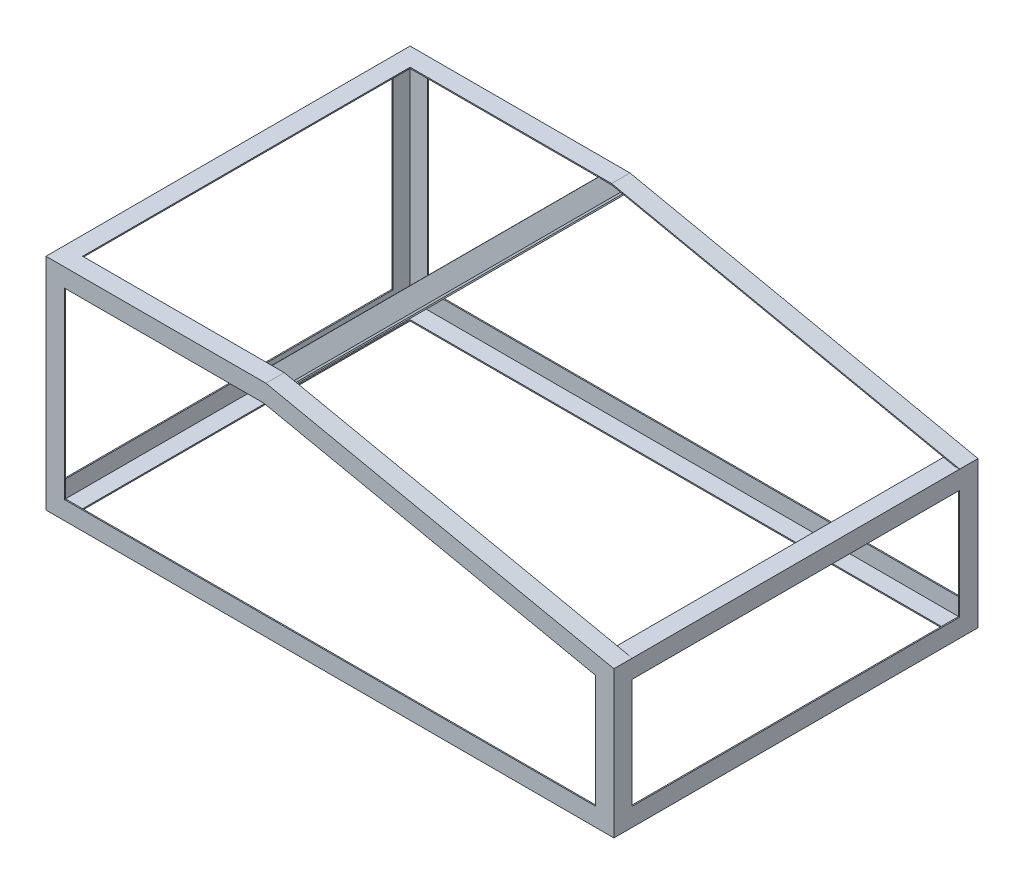
from build123d import *

# Parameters (mm, degrees)
BOTTOM_HORIZONTAL_ANGLE_DEPTH   = 1574.8
BOTTOM_HORIZONTAL_ANGLE_2_DEPTH = 1574.8
FRONT_VERTIAL_ANGLE_DEPTH       = 406.4
REAR_VERTICAL_ANGLE_DEPTH       = 609.6
REAR_TOP_HORIZONTAL_ANGLE_DEPTH = 609.6
BOSS_EXTRUDE5_DEPTH             = 986.357582
BOSS_EXTRUDE6_REACH             = 1011.65


with BuildPart() as part:
    # Sketch5 → Bottom Horizontal Angle (new body)
    with BuildSketch(Plane(origin=(0, 0, 0), x_dir=(0, 0, -1), z_dir=(1, 0, 0))):
        Polygon((-504.825, -304.8), (-504.825, -254), (-501.65, -254), (-501.65, -301.625), (-454.025, -301.625), (-454.025, -304.8), align=None)
    extrude(amount=BOTTOM_HORIZONTAL_ANGLE_DEPTH)



with BuildPart() as body_2:
    # Sketch5 → Bottom Horizontal Angle 2 (new body)
    with BuildSketch(Plane(origin=(0, 0, 0), x_dir=(0, 0, -1), z_dir=(1, 0, 0))):
        Polygon((501.65, -254), (504.825, -254), (504.825, -304.8), (454.025, -304.8), (454.025, -301.625), (501.65, -301.625), align=None)
    extrude(amount=BOTTOM_HORIZONTAL_ANGLE_2_DEPTH)


with BuildPart() as part_1:
    add(part.part)

    add(body_2.part)  # Front Vertial Angle merges body 2
    # Sketch6 → Front Vertial Angle (add)
    with BuildSketch(Plane.XZ.offset(304.8)):
        Polygon((1574.8, -504.825), (1524, -504.825), (1524, -501.65), (1571.625, -501.65), (1571.625, -454.025), (1574.8, -454.025), align=None)
        Polygon((1524, 501.65), (1524, 504.825), (1574.8, 504.825), (1574.8, 454.025), (1571.625, 454.025), (1571.625, 501.65), align=None)
    extrude(amount=-FRONT_VERTIAL_ANGLE_DEPTH)

    # Sketch7 → Rear Vertical Angle (add)
    with BuildSketch(Plane.XZ.offset(304.8)):
        Polygon((0, 504.825), (50.8, 504.825), (50.8, 501.65), (3.175, 501.65), (3.175, 454.025), (0, 454.025), align=None)
        Polygon((50.8, -501.65), (50.8, -504.825), (0, -504.825), (0, -454.025), (3.175, -454.025), (3.175, -501.65), align=None)
    extrude(amount=-REAR_VERTICAL_ANGLE_DEPTH)

    # Sketch8 → Rear Top Horizontal Angle (add)
    with BuildSketch(Plane.ZY):
        Polygon((504.825, 304.8), (504.825, 254), (501.65, 254), (501.65, 301.625), (454.025, 301.625), (454.025, 304.8), align=None)
        Polygon((-501.65, 254), (-504.825, 254), (-504.825, 304.8), (-454.025, 304.8), (-454.025, 301.625), (-501.65, 301.625), align=None)
    extrude(amount=-REAR_TOP_HORIZONTAL_ANGLE_DEPTH)

    # Sketch10 → Boss-Extrude5 (add)
    with BuildSketch(Plane(origin=(522.283289125, -109.954376658, 0), x_dir=(0, 0, -1), z_dir=(0.978549785, -0.206010481, 0))):
        Polygon((504.825, 423.845963712), (504.825, 373.045963712), (501.65, 373.045963712), (501.65, 420.670963712), (454.025, 420.670963712), (454.025, 423.845963712), align=None)
        Polygon((-501.65, 373.045963712), (-504.825, 373.045963712), (-504.825, 423.845963712), (-454.025, 423.845963712), (-454.025, 420.670963712), (-501.65, 420.670963712), align=None)
    extrude(amount=BOSS_EXTRUDE5_DEPTH)

    # Sketch11 → Boss-Extrude6 (add, up to next)
    with BuildSketch(Plane(origin=(0, 0, -504.825), x_dir=(-1, 0, 0), z_dir=(0, 0, -1)), mode=Mode.PRIVATE) as boss_extrude6_sk1:
        Polygon((-1574.8, 101.6), (-1524, 101.6), (-1524, 98.425), (-1571.625, 98.425), (-1571.625, 50.8), (-1574.8, 50.8), align=None)
    boss_extrude6_tool1 = extrude(boss_extrude6_sk1.sketch, amount=-BOSS_EXTRUDE6_REACH, mode=Mode.PRIVATE) - part_1.part
    add(boss_extrude6_tool1.solids().sort_by_distance((1549.4, 100.88158, -504.825))[0])
    # Sketch11 → Boss-Extrude6 (add, up to next)
    with BuildSketch(Plane(origin=(0, 0, -504.825), x_dir=(-1, 0, 0), z_dir=(0, 0, -1)), mode=Mode.PRIVATE) as boss_extrude6_sk2:
        Polygon((-1524, -301.625), (-1524, -304.8), (-1574.8, -304.8), (-1574.8, -254), (-1571.625, -254), (-1571.625, -301.625), align=None)
    boss_extrude6_tool2 = extrude(boss_extrude6_sk2.sketch, amount=-BOSS_EXTRUDE6_REACH, mode=Mode.PRIVATE) - part_1.part
    add(boss_extrude6_tool2.solids().sort_by_distance((1524.71842, -303.2125, -504.825))[0])
    # Sketch11 → Boss-Extrude6 (add, up to next)
    with BuildSketch(Plane(origin=(0, 0, -504.825), x_dir=(-1, 0, 0), z_dir=(0, 0, -1)), mode=Mode.PRIVATE) as boss_extrude6_sk3:
        Polygon((0, -304.8), (-50.8, -304.8), (-50.8, -301.625), (-3.175, -301.625), (-3.175, -254), (0, -254), align=None)
    boss_extrude6_tool3 = extrude(boss_extrude6_sk3.sketch, amount=-BOSS_EXTRUDE6_REACH, mode=Mode.PRIVATE) - part_1.part
    add(boss_extrude6_tool3.solids().sort_by_distance((25.4, -304.08158, -504.825))[0])
    # Sketch11 → Boss-Extrude6 (add, up to next)
    with BuildSketch(Plane(origin=(0, 0, -504.825), x_dir=(-1, 0, 0), z_dir=(0, 0, -1)), mode=Mode.PRIVATE) as boss_extrude6_sk4:
        Polygon((-3.175, 301.625), (-50.8, 301.625), (-50.8, 304.8), (0, 304.8), (0, 254), (-3.175, 254), align=None)
    boss_extrude6_tool4 = extrude(boss_extrude6_sk4.sketch, amount=-BOSS_EXTRUDE6_REACH, mode=Mode.PRIVATE) - part_1.part
    add(boss_extrude6_tool4.solids().sort_by_distance((26.9875, 302.34342, -504.825))[0])
    # Sketch11 → Boss-Extrude6 (add, up to next)
    with BuildSketch(Plane(origin=(0, 0, -504.825), x_dir=(-1, 0, 0), z_dir=(0, 0, -1)), mode=Mode.PRIVATE) as boss_extrude6_sk5:
        Polygon((-605.340190101, 263.281530829), (-644.735373854, 295.354252838), (-642.730828729, 297.816451822), (-605.79784396, 267.748274939), (-575.729667077, 304.681259707), (-573.267468092, 302.676714582), align=None)
    boss_extrude6_tool5 = extrude(boss_extrude6_sk5.sketch, amount=-BOSS_EXTRUDE6_REACH, mode=Mode.PRIVATE) - part_1.part
    add(boss_extrude6_tool5.solids().sort_by_distance((624.516329, 279.958397, -504.825))[0])


solid = part_1.part
